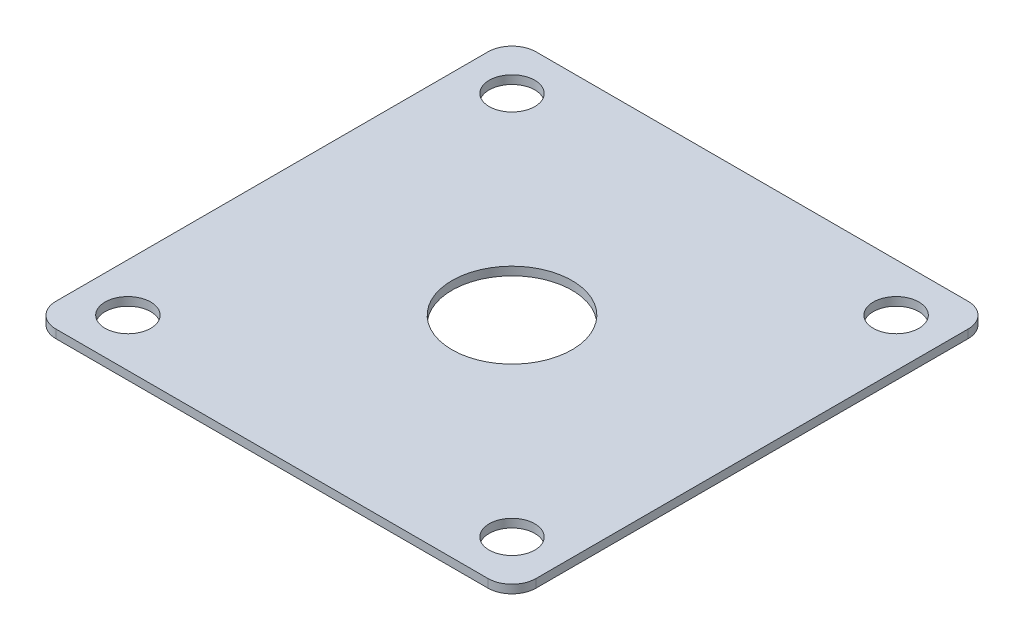
from build123d import *

# Parameters (mm, degrees)
SKETCH1_W           = 50.8
SKETCH1_H           = 50.8
SKETCH1_R           = 6.35
SKETCH1_R_2         = 2.413
BOSS_EXTRUDE1_DEPTH = 0.889
FILLET1_R           = 2.54


with BuildPart() as part:
    # Sketch1 → Boss-Extrude1 (new body)
    with BuildSketch(Plane(origin=(0, 0, 0), x_dir=(1, 0, 0), z_dir=(0, 1, 0))):
        Rectangle(SKETCH1_W, SKETCH1_H)
        Circle(SKETCH1_R, mode=Mode.SUBTRACT)
        with Locations((-20.32, 20.32)):
            Circle(SKETCH1_R_2, mode=Mode.SUBTRACT)
        with Locations((-20.32, -20.32)):
            Circle(SKETCH1_R_2, mode=Mode.SUBTRACT)
        with Locations((20.32, -20.32)):
            Circle(SKETCH1_R_2, mode=Mode.SUBTRACT)
        with Locations((20.32, 20.32)):
            Circle(SKETCH1_R_2, mode=Mode.SUBTRACT)
    extrude(amount=BOSS_EXTRUDE1_DEPTH)

    # Fillet1
    fillet1_edges = [part.edges().sort_by_distance(p)[0] for p in [
        (-25.4, 0.4445, -25.4),
        (25.4, 0.4445, -25.4),
        (25.4, 0.4445, 25.4),
        (-25.4, 0.4445, 25.4),
    ]]
    fillet(fillet1_edges, radius=FILLET1_R)


solid = part.part
